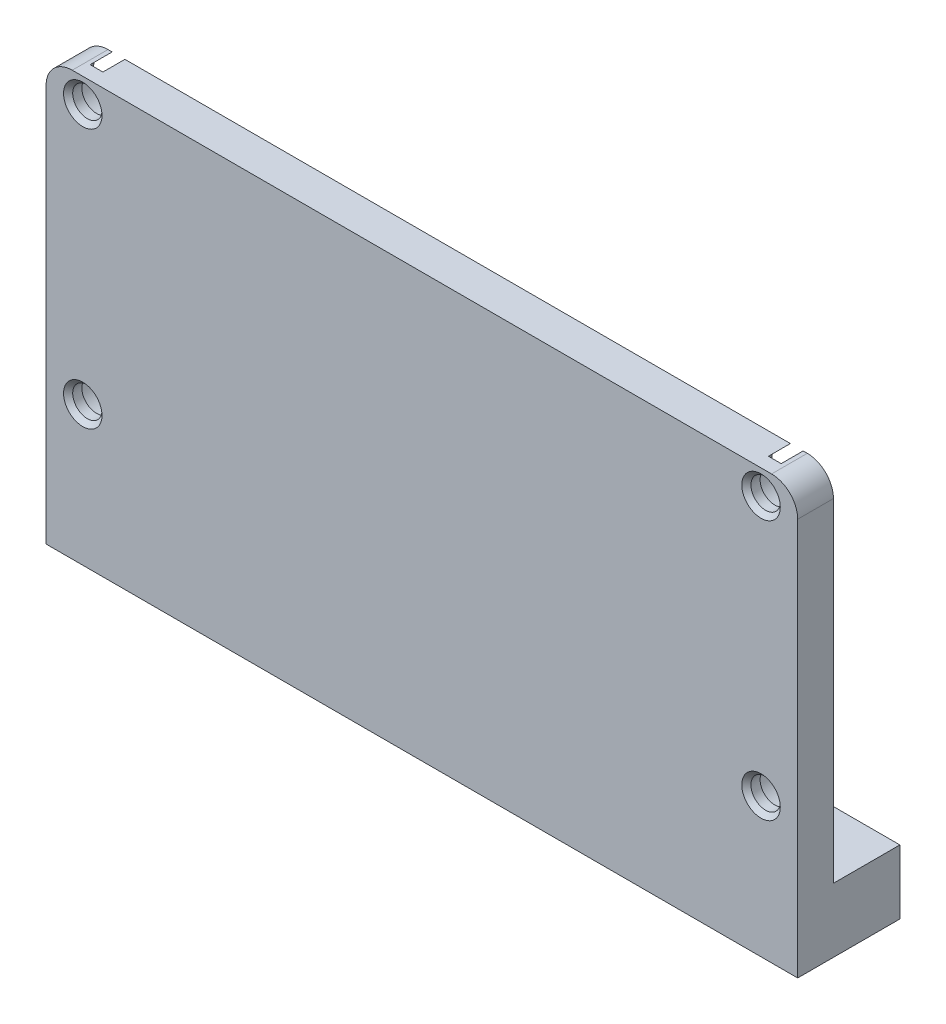
from build123d import *

# Parameters (mm, degrees)
SKETCH1_R                = 1.6
BOSS_EXTRUDE1_DEPTH      = 11.15
SKETCH2_W                = 82
SKETCH2_H                = 0.6
CUT_EXTRUDE1_DEPTH       = 8
CUT_EXTRUDE2_DEPTH       = 46.2
CUT_EXTRUDE3_DEPTH       = 40.2
CUT_EXTRUDE5_DEPTH       = 39.2
BOSS_EXTRUDE2_DEPTH      = 32.2
CHAMFER3_SIZE            = 1.1
CHAMFER4_SIZE            = 1.1
CUT_EXTRUDE12_DEPTH      = 1
CUT_EXTRUDE12_DEPTH_BACK = 83
FILLET3_R                = 15
SKETCH14_R               = 1.6
CUT_EXTRUDE14_DEPTH      = 12.1500001
BOSS_EXTRUDE3_DEPTH      = 3.5
SKETCH8_W                = 82
SKETCH8_H                = 0.6
CUT_EXTRUDE16_DEPTH      = 4.15
SKETCH20_R               = 2.75
CUT_EXTRUDE17_DEPTH      = 2.4
CHAMFER5_SIZE            = 0.5


with BuildPart() as part:
    # Sketch1 → Boss-Extrude1 (new body)
    with BuildSketch(Plane.XY):
        with BuildLine():
            Line((0, -35.2), (82, -35.2))
            Line((82, -35.2), (82, 8.75))
            ThreePointArc((82, 8.75), (81.165254326, 10.765254326), (79.15, 11.6))
            Line((79.15, 11.6), (2.85, 11.6))
            ThreePointArc((2.85, 11.6), (0.834745674, 10.765254326), (0, 8.75))
            Line((0, 8.75), (0, -35.2))
        make_face()
        with Locations((4, 8.939640599)):
            Circle(SKETCH1_R, mode=Mode.SUBTRACT)
        with Locations((78, 8.939640599)):
            Circle(SKETCH1_R, mode=Mode.SUBTRACT)
    extrude(amount=BOSS_EXTRUDE1_DEPTH)

    # Sketch2 → Cut-Extrude1 (cut)
    with BuildSketch(Plane(origin=(0, 0, 0), x_dir=(-1, 0, 0), z_dir=(0, 0, -1))):
        with Locations((-41, -34.9)):
            Rectangle(SKETCH2_W, SKETCH2_H)
    cut_extrude1 = extrude(amount=-CUT_EXTRUDE1_DEPTH, mode=Mode.SUBTRACT)

    # Sketch3 → Cut-Extrude2 (cut)
    with BuildSketch(Plane.XZ.offset(34.6)):
        with BuildLine():
            Line((25.85, 4), (25.85, 0))
            Line((25.85, 0), (29.15, 0))
            Line((29.15, 0), (29.15, 4))
            ThreePointArc((29.15, 4), (27.5, 5.65), (25.85, 4))
        make_face()
        with BuildLine():
            ThreePointArc((14.15, 4), (12.5, 5.65), (10.85, 4))
            Line((10.85, 4), (10.85, 0))
            Line((10.85, 0), (14.15, 0))
            Line((14.15, 0), (14.15, 4))
        make_face()
        with BuildLine():
            ThreePointArc((23.25, 4), (20, 7.25), (16.75, 4))
            Line((16.75, 4), (16.75, 0))
            Line((16.75, 0), (23.25, 0))
            Line((23.25, 0), (23.25, 4))
        make_face()
    cut_extrude2 = extrude(amount=-CUT_EXTRUDE2_DEPTH, mode=Mode.SUBTRACT)

    # Sketch4 → Cut-Extrude3 (cut)
    with BuildSketch(Plane(origin=(0, 11.6, 0), x_dir=(1, 0, 0), z_dir=(0, 1, 0))):
        with BuildLine():
            Line((9.25, -4), (9.25, 0))
            Line((9.25, 0), (15.75, 0))
            Line((15.75, 0), (15.75, -4))
            ThreePointArc((15.75, -4), (12.5, -7.25), (9.25, -4))
        make_face()
        with BuildLine():
            Line((24.25, -4), (24.25, 0))
            Line((24.25, 0), (30.75, 0))
            Line((30.75, 0), (30.75, -4))
            ThreePointArc((30.75, -4), (27.5, -7.25), (24.25, -4))
        make_face()
    cut_extrude3 = extrude(amount=-CUT_EXTRUDE3_DEPTH, mode=Mode.SUBTRACT)

    # Sketch6 → Cut-Extrude5 (cut)
    with BuildSketch(Plane(origin=(0, 11.6, 0), x_dir=(1, 0, 0), z_dir=(0, 1, 0))):
        with BuildLine():
            Line((15.75, -4), (15.75, 0))
            Line((15.75, 0), (15.75, 1.061213364))
            Line((15.75, 1.061213364), (0, 1.061213364))
            Line((0, 1.061213364), (0, -7.25))
            Line((0, -7.25), (12.5, -7.25))
            ThreePointArc((12.5, -7.25), (14.798097039, -6.298097039), (15.75, -4))
        make_face()
        with BuildLine():
            Line((24.25, 0), (24.25, -4))
            ThreePointArc((24.25, -4), (25.201902961, -6.298097039), (27.5, -7.25))
            Line((27.5, -7.25), (41, -7.25))
            Line((41, -7.25), (41, 0))
            Line((41, 0), (24.25, 0))
        make_face()
    cut_extrude5 = extrude(amount=-CUT_EXTRUDE5_DEPTH, mode=Mode.SUBTRACT)

    # Mirror1: Cut-Extrude1, Cut-Extrude2, Cut-Extrude3, Cut-Extrude5 across plane
    add(cut_extrude1.mirror(Plane.ZY.offset(-41)), mode=Mode.SUBTRACT)
    add(cut_extrude2.mirror(Plane.ZY.offset(-41)), mode=Mode.SUBTRACT)
    add(cut_extrude3.mirror(Plane.ZY.offset(-41)), mode=Mode.SUBTRACT)
    add(cut_extrude5.mirror(Plane.ZY.offset(-41)), mode=Mode.SUBTRACT)

    # Sketch12 → Boss-Extrude2 (add)
    with BuildSketch(Plane(origin=(0, 11.6, 0), x_dir=(1, 0, 0), z_dir=(0, 1, 0))):
        with BuildLine():
            Line((16.75, -4), (16.75, 0))
            Line((16.75, 0), (18, 0))
            Line((18, 0), (18.11, -3.084631222))
            ThreePointArc((18.11, -3.084631222), (20, -6.1), (21.89, -3.084631222))
            Line((21.89, -3.084631222), (22, 0))
            Line((22, 0), (23.25, 0))
            Line((23.25, 0), (23.25, -4))
            ThreePointArc((23.25, -4), (20, -7.25), (16.75, -4))
        make_face()
        with BuildLine():
            Line((58.75, -4), (58.75, 0))
            Line((58.75, 0), (60.05, 0))
            Line((60.05, 0), (60.155, -3.106425717))
            ThreePointArc((60.155, -3.106425717), (62, -6.05), (63.845, -3.106425717))
            Line((63.845, -3.106425717), (63.95, 0))
            Line((63.95, 0), (65.25, 0))
            Line((65.25, 0), (65.25, -4))
            ThreePointArc((65.25, -4), (62, -7.25), (58.75, -4))
        make_face()
    extrude(amount=-BOSS_EXTRUDE2_DEPTH)

    # Chamfer3
    chamfer3_edges = [part.edges().sort_by_distance(p)[0] for p in [
        (65.25, -20.6, 2),
        (58.75, -20.6, 2),
        (62, -20.6, 7.25),
    ]]
    chamfer(chamfer3_edges, length=CHAMFER3_SIZE)

    # Chamfer4
    chamfer4_edges = [part.edges().sort_by_distance(p)[0] for p in [
        (23.25, -20.6, 2),
        (16.75, -20.6, 2),
        (20, -20.6, 7.25),
    ]]
    chamfer(chamfer4_edges, length=CHAMFER4_SIZE)

    # Sketch9 → Cut-Extrude12 (cut, two sides)
    with BuildSketch(Plane.ZY) as cut_extrude12_sk:
        Polygon((-106.219800457, 11.6), (0, 11.6), (7.25, 11.6), (0, 2.4), (-65.744961499, -81.028089075), (-260.411588221, -166.089763625), (-300.886427179, -73.46167455), align=None)
    extrude(amount=CUT_EXTRUDE12_DEPTH, mode=Mode.SUBTRACT)
    extrude(cut_extrude12_sk.sketch, amount=-CUT_EXTRUDE12_DEPTH_BACK, mode=Mode.SUBTRACT)

    # Fillet3
    fillet3_edges = [part.edges().sort_by_distance(p)[0] for p in [
        (16.875, 2.4, 0),
        (23.125, 2.4, 0),
        (58.9, 2.4, 0),
        (65.1, 2.4, 0),
    ]]
    fillet(fillet3_edges, radius=FILLET3_R)

    # Sketch14 → Cut-Extrude14 (cut, through all)
    with BuildSketch(Plane.XY.offset(11.15)):
        with Locations((4, -19.400359401)):
            Circle(SKETCH14_R)
    cut_extrude14 = extrude(amount=-CUT_EXTRUDE14_DEPTH, mode=Mode.SUBTRACT)

    # Mirror3: Cut-Extrude14 across plane
    add(cut_extrude14.mirror(Plane.ZY.offset(-41)), mode=Mode.SUBTRACT)

    # Sketch18 → Boss-Extrude3 (add)
    with BuildSketch(Plane(origin=(0, -27.6, 0), x_dir=(1, 0, 0), z_dir=(0, 1, 0))):
        with BuildLine():
            Line((14.15, 0), (14.15, -1.2))
            ThreePointArc((14.15, -1.2), (15.321790212, -2.38754845), (15.75, -4))
            Line((15.75, -4), (15.75, 0))
            Line((15.75, 0), (14.15, 0))
        make_face()
        with BuildLine():
            Line((10.85, -1.2), (10.85, 0))
            Line((10.85, 0), (9.25, 0))
            Line((9.25, 0), (9.25, -4))
            ThreePointArc((9.25, -4), (9.678209788, -2.38754845), (10.85, -1.2))
        make_face()
        with BuildLine():
            Line((29.15, 0), (29.15, -1.2))
            ThreePointArc((29.15, -1.2), (30.321790212, -2.38754845), (30.75, -4))
            Line((30.75, -4), (30.75, 0))
            Line((30.75, 0), (29.15, 0))
        make_face()
        with BuildLine():
            Line((25.85, -1.2), (25.85, 0))
            Line((25.85, 0), (24.25, 0))
            Line((24.25, 0), (24.25, -4))
            ThreePointArc((24.25, -4), (24.678209788, -2.38754845), (25.85, -1.2))
        make_face()
    boss_extrude3 = extrude(amount=-BOSS_EXTRUDE3_DEPTH)

    # Mirror5: Boss-Extrude3 across plane
    add(boss_extrude3.mirror(Plane.ZY.offset(-41)))

    # Sketch8 → Cut-Extrude16 (cut, through all)
    with BuildSketch(Plane(origin=(0, 0, 8), x_dir=(-1, 0, 0), z_dir=(0, 0, -1))):
        with Locations((-41, -34.9)):
            Rectangle(SKETCH8_W, SKETCH8_H)
    extrude(amount=-CUT_EXTRUDE16_DEPTH, mode=Mode.SUBTRACT)

    # Sketch20 → Cut-Extrude17 (cut)
    with BuildSketch(Plane(origin=(0, 0, 7.25), x_dir=(-1, 0, 0), z_dir=(0, 0, -1))):
        with Locations((-78, 8.939640599)):
            Circle(SKETCH20_R)
        with Locations((-78, -19.400359401)):
            Circle(SKETCH20_R)
    cut_extrude17 = extrude(amount=-CUT_EXTRUDE17_DEPTH, mode=Mode.SUBTRACT)

    # Mirror7: Cut-Extrude17 across plane
    add(cut_extrude17.mirror(Plane.ZY.offset(-41)), mode=Mode.SUBTRACT)

    # Chamfer5
    chamfer5_edges = [part.edges().sort_by_distance(p)[0] for p in [
        (2.4, 8.939640599, 11.15),
        (76.4, 8.939640599, 11.15),
        (2.4, -19.400359401, 11.15),
        (79.6, -19.400359401, 11.15),
    ]]
    chamfer(chamfer5_edges, length=CHAMFER5_SIZE)


solid = part.part
